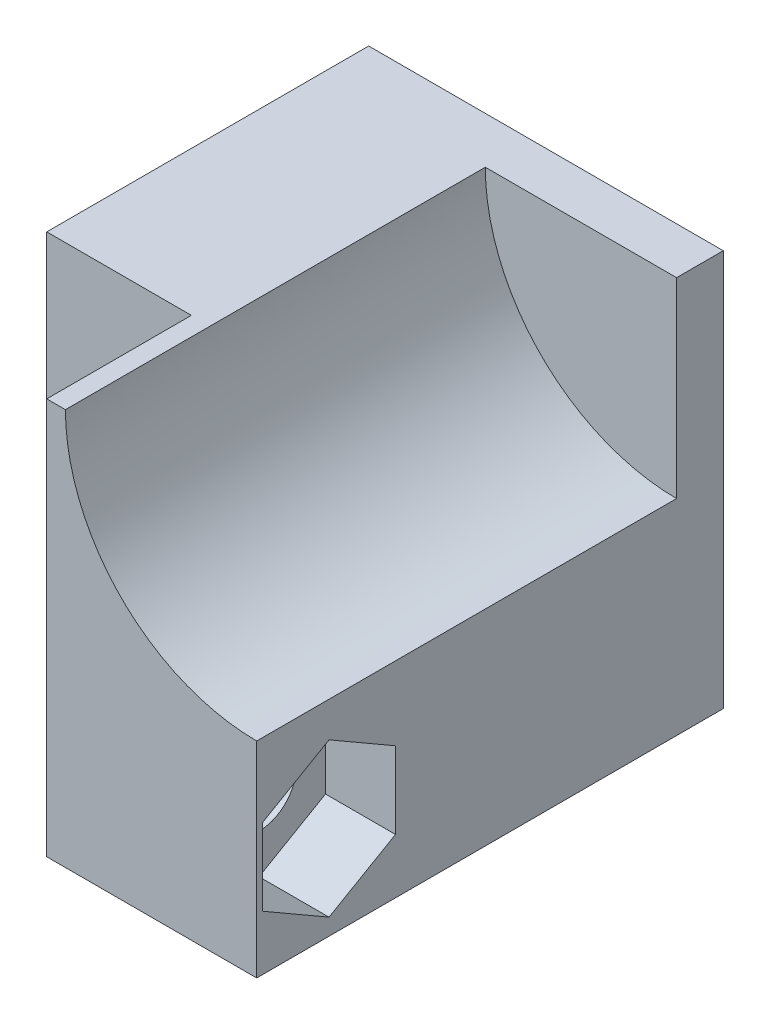
from build123d import *

# Parameters (mm, degrees)
CROQUIS1_W              = 15.2
CROQUIS1_H              = 17
SALIENTE_EXTRUIR1_DEPTH = 2
SALIENTE_EXTRUIR2_DEPTH = 11.8
SALIENTE_EXTRUIR3_DEPTH = 6.2
CORTAR_EXTRUIR1_REACH   = 11
CROQUIS4_R              = 1.6
CORTAR_EXTRUIR2_DEPTH   = 3


with BuildPart() as part:
    # Croquis1 → Saliente-Extruir1 (new body)
    with BuildSketch(Plane.XY):
        with Locations((7.6, 8.5)):
            Rectangle(CROQUIS1_W, CROQUIS1_H)
    extrude(amount=SALIENTE_EXTRUIR1_DEPTH)

    # Croquis2 → Saliente-Extruir2 (add)
    with BuildSketch(Plane.XY.offset(2)):
        with BuildLine():
            Line((0, 17), (0, 0))
            Line((0, 0), (15.2, 0))
            Line((15.2, 0), (15.2, 8.8))
            ThreePointArc((15.2, 8.8), (9.401724394, 11.201724394), (7, 17))
            Line((7, 17), (0, 17))
        make_face()
    extrude(amount=SALIENTE_EXTRUIR2_DEPTH)

    # Croquis3 → Saliente-Extruir3 (add)
    with BuildSketch(Plane.XY.offset(13.8)):
        with BuildLine():
            Line((6.2, 17), (6.2, 0))
            Line((6.2, 0), (15.2, 0))
            Line((15.2, 0), (15.2, 8.8))
            ThreePointArc((15.2, 8.8), (9.401724394, 11.201724394), (7, 17))
            Line((7, 17), (6.2, 17))
        make_face()
    extrude(amount=SALIENTE_EXTRUIR3_DEPTH)

    # Croquis4 → Cortar-Extruir1 (cut, up to next)
    with BuildSketch(Plane.ZY.offset(-6.2), mode=Mode.PRIVATE) as cortar_extruir1_sk1:
        with Locations((16.9, 4)):
            Circle(CROQUIS4_R)
    cortar_extruir1_tool1 = extrude(cortar_extruir1_sk1.sketch, amount=-CORTAR_EXTRUIR1_REACH, mode=Mode.PRIVATE) & part.part
    add(cortar_extruir1_tool1.solids().sort_by_distance((6.2, 4, 16.9))[0], mode=Mode.SUBTRACT)

    # Croquis5 → Cortar-Extruir2 (cut)
    with BuildSketch(Plane(origin=(15.2, 0, 0), x_dir=(0, 0, -1), z_dir=(1, 0, 0))):
        Polygon((-16.9, 0.709103466), (-14.05, 2.354551733), (-14.05, 5.645448267), (-16.9, 7.290896534), (-19.75, 5.645448267), (-19.75, 2.354551733), align=None)
    extrude(amount=-CORTAR_EXTRUIR2_DEPTH, mode=Mode.SUBTRACT)


solid = part.part
